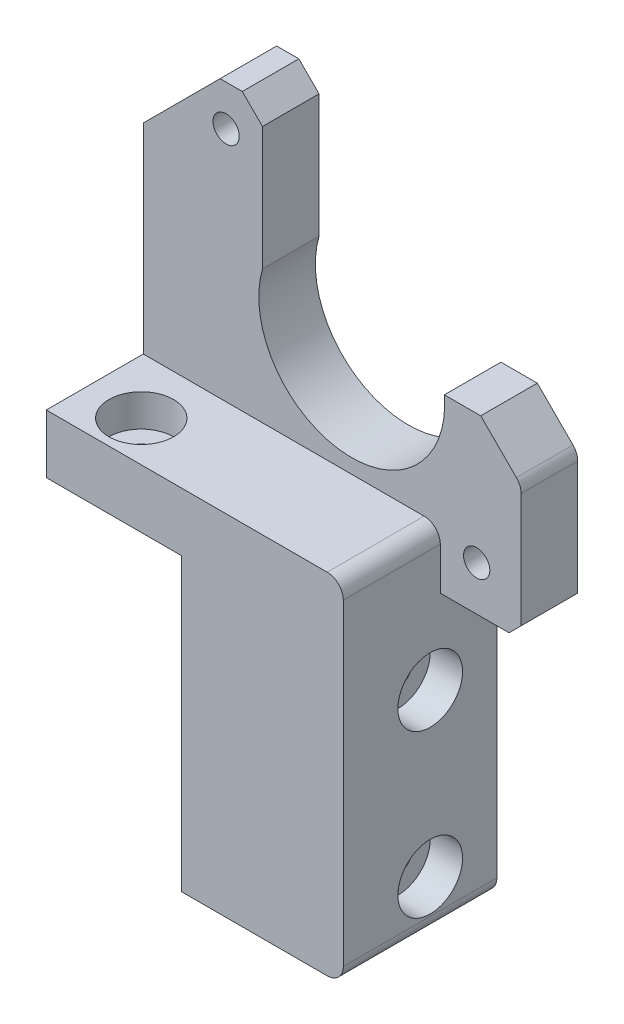
from build123d import *

# Parameters (mm, degrees)
BOSS_EXTRUDE1_DEPTH = 19
BOSS_EXTRUDE2_DEPTH = 7
SKETCH3_R           = 1.75
CUT_EXTRUDE1_DEPTH  = 37.75
SKETCH6_R           = 4
CUT_EXTRUDE4_DEPTH  = 4
SKETCH7_R           = 1.625
CUT_EXTRUDE5_DEPTH  = 20
FILLET1_R           = 2
SKETCH8_R           = 1.75
CUT_EXTRUDE6_DEPTH  = 10
SKETCH9_R           = 4
CUT_EXTRUDE7_DEPTH  = 4


with BuildPart() as part:
    # Sketch1 → Boss-Extrude1 (new body)
    with BuildSketch(Plane.XY):
        Polygon((0, 0), (20, 0), (20, 43.25), (-16.75, 43.25), (-16.75, 36), (0, 36), align=None)
    extrude(amount=BOSS_EXTRUDE1_DEPTH)

    # Sketch2 → Boss-Extrude2 (add)
    with BuildSketch(Plane(origin=(0, 0, 0), x_dir=(-1, 0, 0), z_dir=(0, 0, -1))):
        with BuildLine():
            Line((-20, 36), (16.75, 36))
            Line((16.75, 36), (16.75, 68))
            Line((16.75, 68), (7.25, 77.5))
            Line((7.25, 77.5), (4.5, 77.5))
            Line((4.5, 77.5), (2, 75))
            Line((2, 75), (2, 59.75))
            ThreePointArc((2, 59.75), (-7.896468276, 45.089682755), (-20.5, 57.5))
            Line((-20.5, 57.5), (-25, 57.5))
            Line((-25, 57.5), (-30, 52.5))
            Line((-30, 52.5), (-30, 37.5))
            Line((-30, 37.5), (-28.5, 36))
            Line((-28.5, 36), (-20, 36))
        make_face()
    extrude(amount=-BOSS_EXTRUDE2_DEPTH)

    # Sketch3 → Cut-Extrude1 (cut, through all)
    with BuildSketch(Plane(origin=(20, 0, 0), x_dir=(0, 0, -1), z_dir=(1, 0, 0))):
        with Locations((-8.25, 26.25)):
            Circle(SKETCH3_R)
        with Locations((-8.25, 6.25)):
            Circle(SKETCH3_R)
    extrude(amount=-CUT_EXTRUDE1_DEPTH, mode=Mode.SUBTRACT)

    # Sketch6 → Cut-Extrude4 (cut)
    with BuildSketch(Plane(origin=(20, 0, 0), x_dir=(0, 0, -1), z_dir=(1, 0, 0))):
        with Locations((-8.25, 26.25)):
            Circle(SKETCH6_R)
        with Locations((-8.25, 6.25)):
            Circle(SKETCH6_R)
    extrude(amount=-CUT_EXTRUDE4_DEPTH, mode=Mode.SUBTRACT)

    # Sketch7 → Cut-Extrude5 (cut, through all)
    with BuildSketch(Plane(origin=(0, 0, 0), x_dir=(-1, 0, 0), z_dir=(0, 0, -1))):
        with Locations((6.5, 72.5)):
            Circle(SKETCH7_R)
        with Locations((-24.5, 41.5)):
            Circle(SKETCH7_R)
    extrude(amount=-CUT_EXTRUDE5_DEPTH, mode=Mode.SUBTRACT)

    # Fillet1
    fillet1_edges = [part.edges().sort_by_distance(p)[0] for p in [
        (20, 43.25, 13),
        (20, 0, 9.5),
        (30, 52.5, 3.5),
    ]]
    fillet(fillet1_edges, radius=FILLET1_R)

    # Sketch8 → Cut-Extrude6 (cut)
    with BuildSketch(Plane.XZ.offset(-36)):
        with Locations((-10, 14)):
            Circle(SKETCH8_R)
    extrude(amount=-CUT_EXTRUDE6_DEPTH, mode=Mode.SUBTRACT)

    # Sketch9 → Cut-Extrude7 (cut)
    with BuildSketch(Plane(origin=(0, 43.25, 0), x_dir=(1, 0, 0), z_dir=(0, 1, 0))):
        with Locations((-10, -14)):
            Circle(SKETCH9_R)
    extrude(amount=-CUT_EXTRUDE7_DEPTH, mode=Mode.SUBTRACT)


solid = part.part
